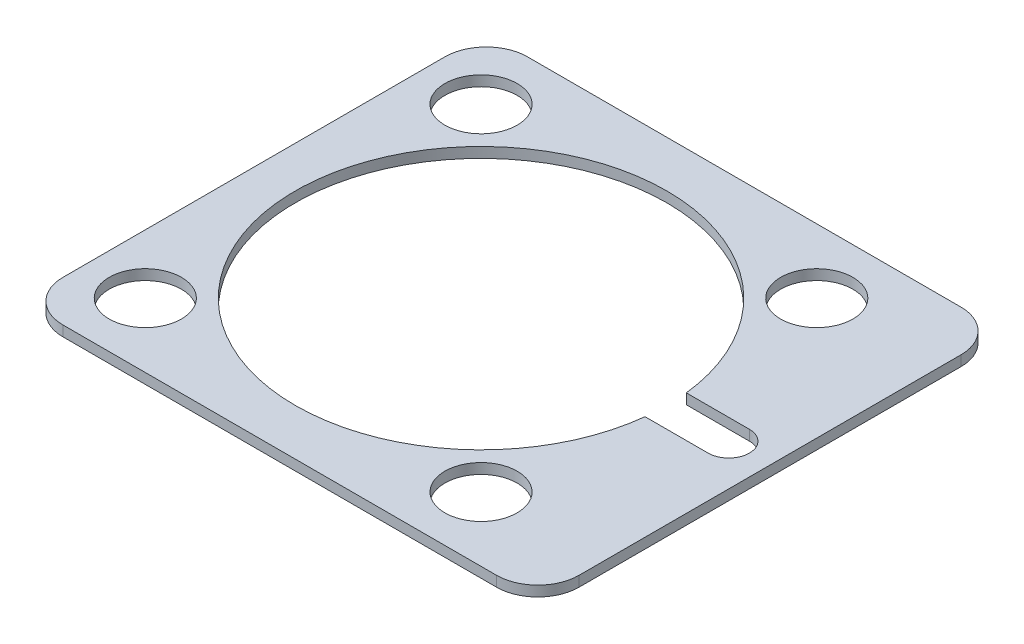
from build123d import *

# Parameters (mm, degrees)
SKETCH1_W         = 50
SKETCH1_H         = 45
BODY_DEPTH        = 0.5
CENTER_HOLE_DEPTH = 2
SKETCH3_R         = 3.5
HOLE_1_DEPTH      = 2
HOLES_2_4_COUNT   = 4
R4_FILLETS_R      = 4


with BuildPart() as part:
    # Sketch1 → Body (new body, symmetric)
    with BuildSketch(Plane(origin=(0, 0, 0), x_dir=(1, 0, 0), z_dir=(0, 1, 0))):
        with Locations((3, 0)):
            Rectangle(SKETCH1_W, SKETCH1_H)
    extrude(amount=BODY_DEPTH, both=True)

    # Sketch2 → Center hole (cut, through all)
    with BuildSketch(Plane(origin=(0, 0.5, 0), x_dir=(1, 0, 0), z_dir=(0, 1, 0))):
        with BuildLine():
            Line((17.88854382, 2), (24, 2))
            ThreePointArc((24, 2), (26, 0), (24, -2))
            Line((24, -2), (17.88854382, -2))
            ThreePointArc((17.88854382, -2), (-18, 0), (17.88854382, 2))
        make_face()
    extrude(amount=-CENTER_HOLE_DEPTH, mode=Mode.SUBTRACT)

    # Sketch3 → Hole 1 (cut, through all)
    with BuildSketch(Plane(origin=(0, 0.5, 0), x_dir=(1, 0, 0), z_dir=(0, 1, 0))):
        with Locations((16.263455967, 16.263455967)):
            Circle(SKETCH3_R)
    hole_1 = extrude(amount=-HOLE_1_DEPTH, mode=Mode.SUBTRACT)

    # Holes 2-4: Hole 1 ×4 about axis
    holes_2_4_axis = Axis((0, 0, 0), (0, 1, 0))
    for i in range(1, HOLES_2_4_COUNT):
        add(hole_1.rotate(holes_2_4_axis, i * 360 / HOLES_2_4_COUNT), mode=Mode.SUBTRACT)

    # R4 Fillets
    r4_fillets_edges = [part.edges().sort_by_distance(p)[0] for p in [
        (-22, 0, -22.5),
        (28, 0, -22.5),
        (28, 0, 22.5),
        (-22, 0, 22.5),
    ]]
    fillet(r4_fillets_edges, radius=R4_FILLETS_R)


solid = part.part
